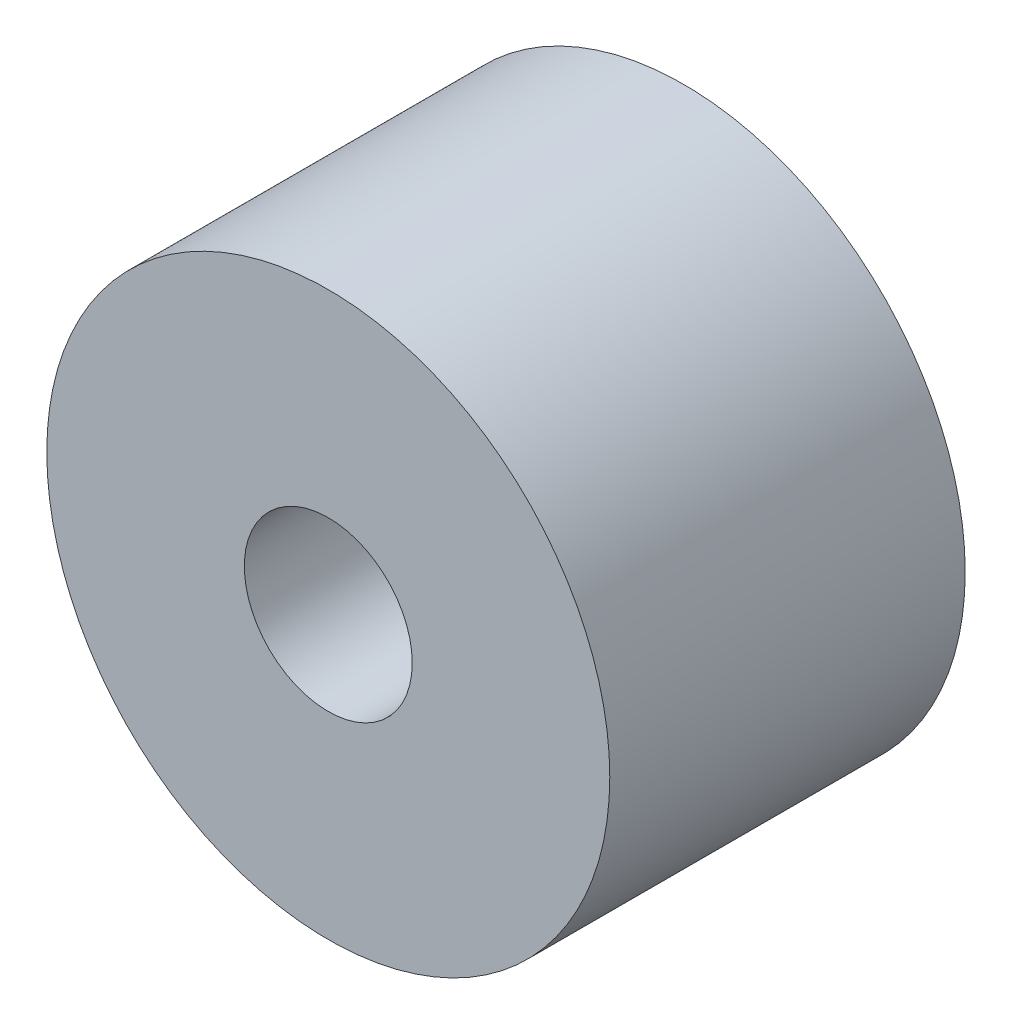
from build123d import *

# Parameters (mm, degrees)
SKETCH1_R           = 10.0584
SKETCH1_R_2         = 3
BOSS_EXTRUDE1_DEPTH = 12.7


with BuildPart() as part:
    # Sketch1 → Boss-Extrude1 (new body)
    with BuildSketch(Plane.XY):
        Circle(SKETCH1_R)
        Circle(SKETCH1_R_2, mode=Mode.SUBTRACT)
    extrude(amount=BOSS_EXTRUDE1_DEPTH)


solid = part.part
